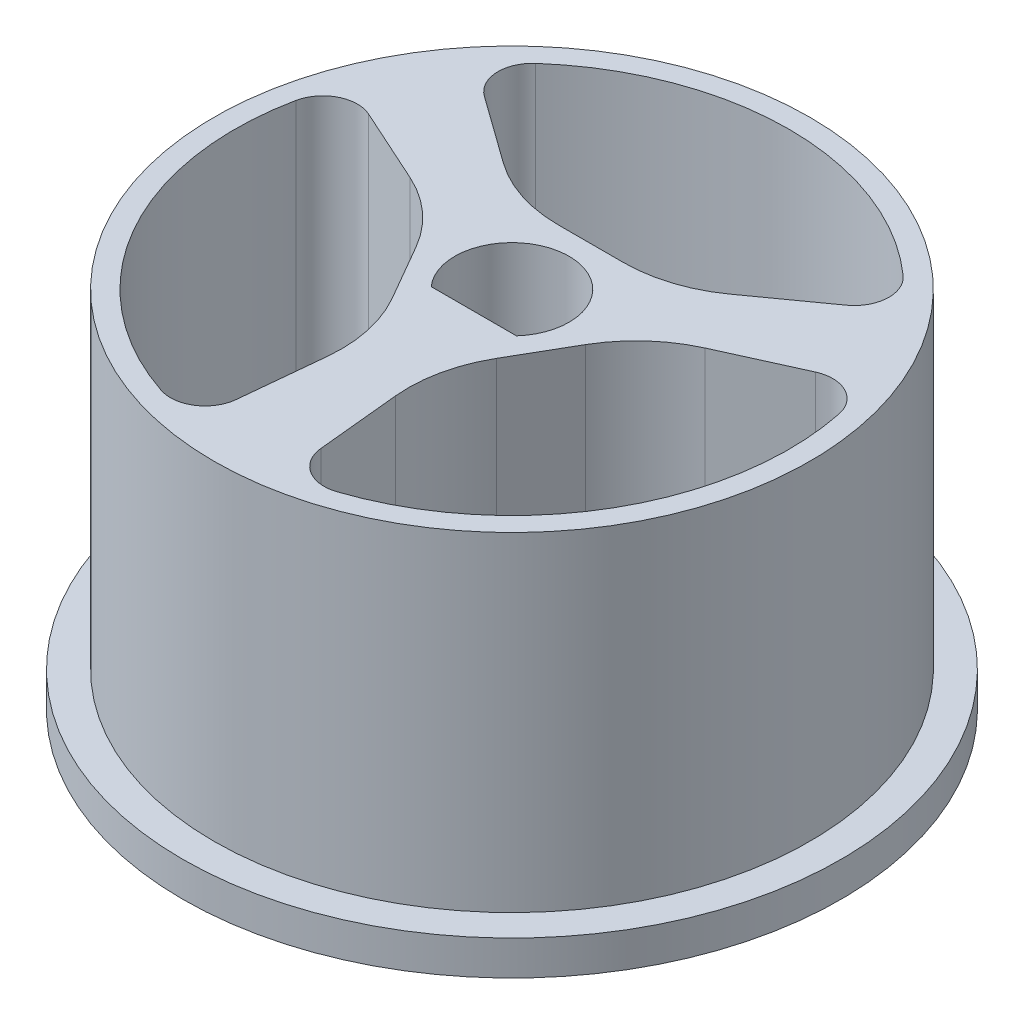
from build123d import *

# Parameters (mm, degrees)
SKETCH_1_R      = 9.5
SKETCH_1_R_2    = 8.6
EXTRUDE_2_DEPTH = 1
SKETCH_1_4_R    = 8.6
EXTRUDE_4_DEPTH = 10.5


with BuildPart() as part:
    # 草图1 → 凸台-拉伸2 (new body)
    with BuildSketch(Plane(origin=(0, 0, 0), x_dir=(1, 0, 0), z_dir=(0, 1, 0))):
        Circle(SKETCH_1_R)
        Circle(SKETCH_1_R_2, mode=Mode.SUBTRACT)
    extrude(amount=EXTRUDE_2_DEPTH)

    # 草图1<4> → 凸台-拉伸4 (add)
    with BuildSketch(Plane(origin=(0, 0, 0), x_dir=(1, 0, 0), z_dir=(0, 1, 0))):
        Circle(SKETCH_1_4_R)
        with BuildLine():
            ThreePointArc((-4.257529302, 1.319914676), (-3.22106843, 0.640114314), (-2.442480608, -0.324344434))
            Line((-2.442480608, -0.324344434), (-1.502130823, -1.953078038))
            ThreePointArc((-1.502130823, -1.953078038), (-1.056178958, -3.109584244), (-0.98568501, -4.347085871))
            Line((-0.98568501, -4.347085871), (-1.222344473, -6.737988124))
            ThreePointArc((-1.222344473, -6.737988124), (-1.673731111, -7.478733269), (-2.534264377, -7.58798419))
            ThreePointArc((-2.534264377, -7.58798419), (-4, -6.92820323), (-5.304254883, -5.988729426))
            ThreePointArc((-5.304254883, -5.988729426), (-6.92820323, -4), (-7.838519261, -1.599254764))
            ThreePointArc((-7.838519261, -1.599254764), (-8, 0), (-7.838519261, 1.599254764))
            ThreePointArc((-7.838519261, 1.599254764), (-7.313638554, 2.289872973), (-6.446441123, 2.310412696))
            Line((-6.446441123, 2.310412696), (-4.257529302, 1.319914676))
        make_face(mode=Mode.SUBTRACT)
        with BuildLine():
            ThreePointArc((2.442480608, -0.324344434), (3.22106843, 0.640114314), (4.257529302, 1.319914676))
            Line((4.257529302, 1.319914676), (6.446441123, 2.310412696))
            ThreePointArc((6.446441123, 2.310412696), (7.313638554, 2.289872973), (7.838519261, 1.599254764))
            ThreePointArc((7.838519261, 1.599254764), (8, 0), (7.838519261, -1.599254764))
            ThreePointArc((7.838519261, -1.599254764), (6.92820323, -4), (5.304254883, -5.988729426))
            ThreePointArc((5.304254883, -5.988729426), (4, -6.92820323), (2.534264377, -7.58798419))
            ThreePointArc((2.534264377, -7.58798419), (1.673731111, -7.478733269), (1.222344473, -6.737988124))
            Line((1.222344473, -6.737988124), (0.98568501, -4.347085871))
            ThreePointArc((0.98568501, -4.347085871), (1.056178958, -3.109584244), (1.502130823, -1.953078038))
            Line((1.502130823, -1.953078038), (2.442480608, -0.324344434))
        make_face(mode=Mode.SUBTRACT)
        with BuildLine():
            Line((5.22409665, 4.427575428), (3.271844291, 3.027171194))
            ThreePointArc((3.271844291, 3.027171194), (2.164889472, 2.469469931), (0.940349784, 2.277422472))
            Line((0.940349784, 2.277422472), (-0.940349784, 2.277422472))
            ThreePointArc((-0.940349784, 2.277422472), (-2.164889472, 2.469469931), (-3.271844291, 3.027171194))
            Line((-3.271844291, 3.027171194), (-5.22409665, 4.427575428))
            ThreePointArc((-5.22409665, 4.427575428), (-5.639907443, 5.188860296), (-5.304254883, 5.988729426))
            ThreePointArc((-5.304254883, 5.988729426), (-4, 6.92820323), (-2.534264377, 7.58798419))
            ThreePointArc((-2.534264377, 7.58798419), (0, 8), (2.534264377, 7.58798419))
            ThreePointArc((2.534264377, 7.58798419), (4, 6.92820323), (5.304254883, 5.988729426))
            ThreePointArc((5.304254883, 5.988729426), (5.639907443, 5.188860296), (5.22409665, 4.427575428))
        make_face(mode=Mode.SUBTRACT)
        with BuildLine():
            Line((1.229837388, -1.1), (-1.229837388, -1.1))
            ThreePointArc((-1.229837388, -1.1), (0, 1.65), (1.229837388, -1.1))
        make_face(mode=Mode.SUBTRACT)
    extrude(amount=EXTRUDE_4_DEPTH)


solid = part.part
